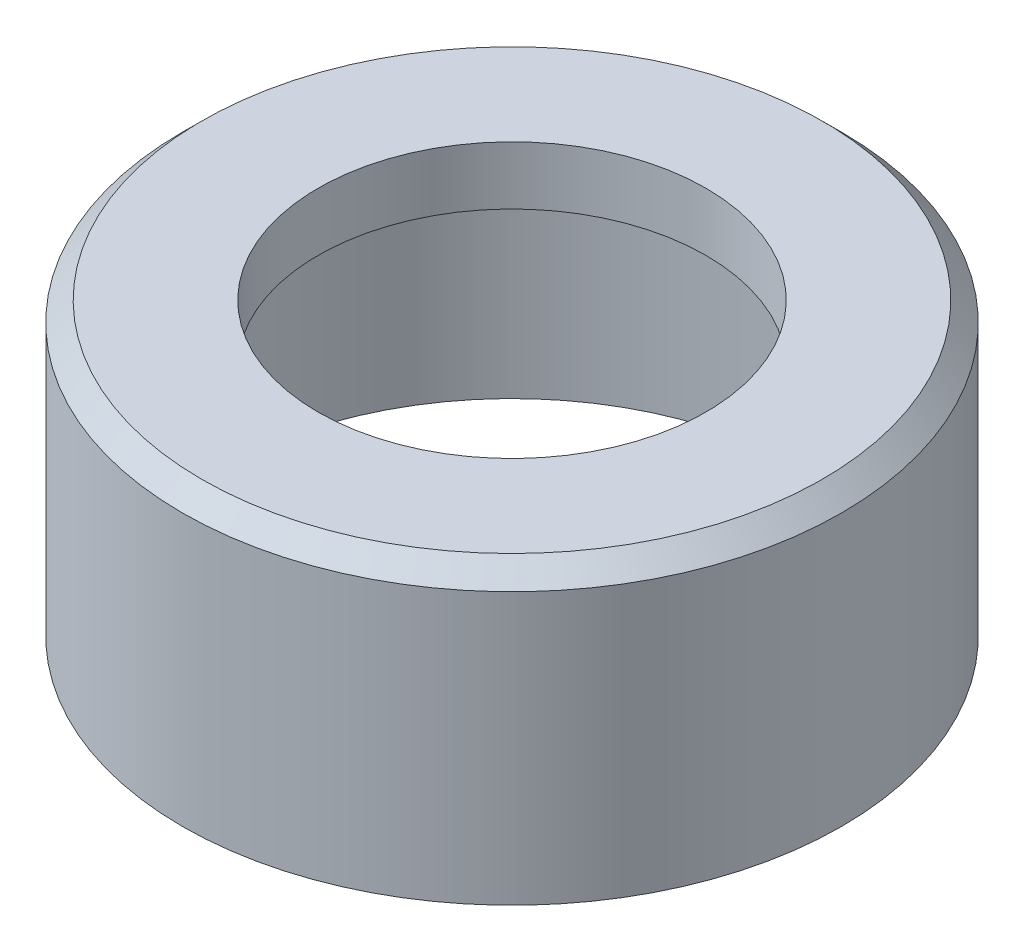
from build123d import *

# Parameters (mm, degrees)
SKETCH1_R           = 8.5
SKETCH1_R_2         = 7.5
BOSS_EXTRUDE1_DEPTH = 6
SKETCH3_R           = 8.5
SKETCH3_R_2         = 5
BOSS_EXTRUDE2_DEPTH = 1.5
CHAMFER1_SIZE       = 0.5


with BuildPart() as part:
    # Sketch1 → Boss-Extrude1 (new body)
    with BuildSketch(Plane(origin=(0, 0, 0), x_dir=(1, 0, 0), z_dir=(0, 1, 0))):
        Circle(SKETCH1_R)
        Circle(SKETCH1_R_2, mode=Mode.SUBTRACT)
    extrude(amount=BOSS_EXTRUDE1_DEPTH)

    # Sketch3 → Boss-Extrude2 (add)
    with BuildSketch(Plane(origin=(0, 6, 0), x_dir=(1, 0, 0), z_dir=(0, 1, 0))):
        Circle(SKETCH3_R)
        Circle(SKETCH3_R_2, mode=Mode.SUBTRACT)
    extrude(amount=BOSS_EXTRUDE2_DEPTH)

    # Chamfer1
    chamfer1_edges = [part.edges().sort_by_distance(p)[0] for p in [
        (-8.5, 7.5, 0),
    ]]
    chamfer(chamfer1_edges, length=CHAMFER1_SIZE)


solid = part.part
